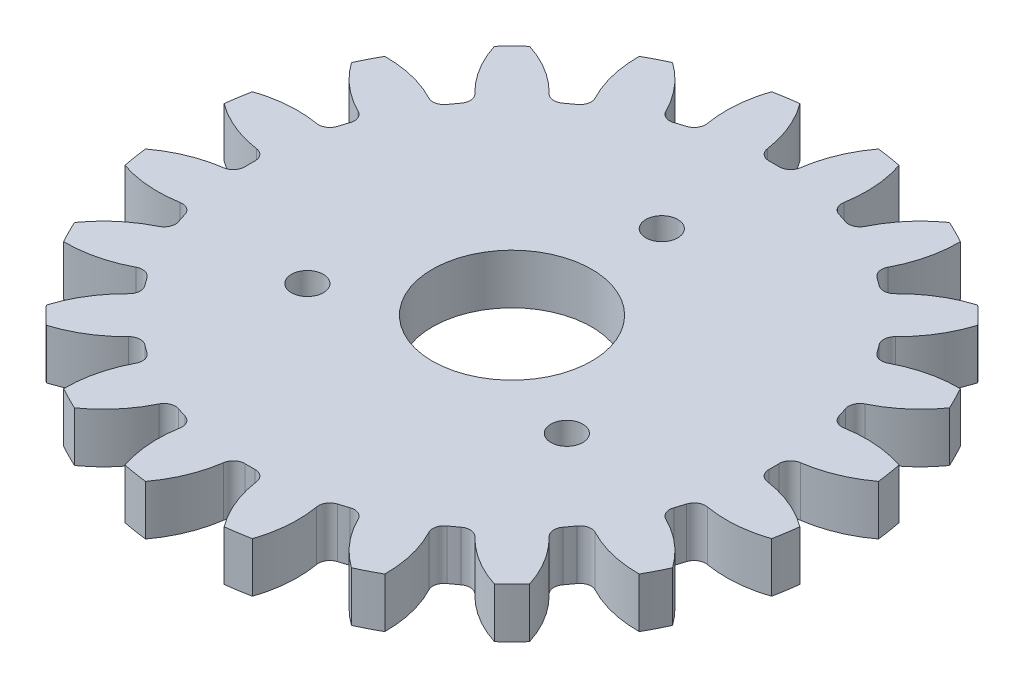
from build123d import *

# Parameters (mm, degrees)
SKETCH2_R                = 33
SKETCH2_R_2              = 7.975
BOSS_EXTRUDE1_DEPTH      = 5
CUT_EXTRUDE1_DEPTH       = 6
FILLET1_R                = 1.14
CIRPATTERN1_COUNT        = 20
FILLET1_OF_CIRPATTERN1_R = 1.14
SKETCH6_R                = 1.6
CUT_EXTRUDE3_DEPTH       = 6.0000001


with BuildPart() as part:
    # Sketch2 → Boss-Extrude1 (new body)
    with BuildSketch(Plane(origin=(0, 0, 0), x_dir=(1, 0, 0), z_dir=(0, 1, 0))):
        Circle(SKETCH2_R)
        Circle(SKETCH2_R_2, mode=Mode.SUBTRACT)
    extrude(amount=BOSS_EXTRUDE1_DEPTH)

    # Sketch3 → Cut-Extrude1 (cut, through all)
    with BuildSketch(Plane(origin=(0, 5, 0), x_dir=(1, 0, 0), z_dir=(0, 1, 0))):
        with BuildLine():
            ThreePointArc((1.54561618, 26.204457076), (0, 26.25), (-1.54561618, 26.204457076))
            ThreePointArc((-1.54561618, 26.204457076), (-2.260255479, 29.659029471), (-3.933366347, 32.764746744))
            ThreePointArc((-3.933366347, 32.764746744), (0, 33), (3.933366347, 32.764746744))
            ThreePointArc((3.933366347, 32.764746744), (2.260255479, 29.659029471), (1.54561618, 26.204457076))
        make_face()
    cut_extrude1 = extrude(amount=-CUT_EXTRUDE1_DEPTH, mode=Mode.SUBTRACT)

    # Fillet1
    fillet1_edges = [part.edges().sort_by_distance(p)[0] for p in [
        (-1.54561618, 2.5, -26.204457076),
        (1.54561618, 2.5, -26.204457076),
    ]]
    fillet(fillet1_edges, radius=FILLET1_R)

    # CirPattern1: Cut-Extrude1 ×20 about axis
    cirpattern1_axis = Axis((0, 0, 0), (0, 1, 0))
    for i in range(1, CIRPATTERN1_COUNT):
        add(cut_extrude1.rotate(cirpattern1_axis, i * 360 / CIRPATTERN1_COUNT), mode=Mode.SUBTRACT)

    # Fillet1 of CirPattern1
    fillet1_of_cirpattern1_edges = [part.edges().sort_by_distance(p)[0] for p in [
        (-9.567590904, 2.5, -24.444297991),
        (-6.627654225, 2.5, -25.399541324),
        (-16.65302317, 2.5, -20.291360706),
        (-14.152163657, 2.5, -22.108341499),
        (-22.108341499, 2.5, -14.152163657),
        (-20.291360706, 2.5, -16.65302317),
        (-25.399541324, 2.5, -6.627654225),
        (-24.444297991, 2.5, -9.567590904),
        (-26.204457076, 2.5, 1.54561618),
        (-26.204457076, 2.5, -1.54561618),
        (-24.444297991, 2.5, 9.567590904),
        (-25.399541324, 2.5, 6.627654225),
        (-20.291360706, 2.5, 16.65302317),
        (-22.108341499, 2.5, 14.152163657),
        (-14.152163657, 2.5, 22.108341499),
        (-16.65302317, 2.5, 20.291360706),
        (-6.627654225, 2.5, 25.399541324),
        (-9.567590904, 2.5, 24.444297991),
        (1.54561618, 2.5, 26.204457076),
        (-1.54561618, 2.5, 26.204457076),
        (9.567590904, 2.5, 24.444297991),
        (6.627654225, 2.5, 25.399541324),
        (16.65302317, 2.5, 20.291360706),
        (14.152163657, 2.5, 22.108341499),
        (22.108341499, 2.5, 14.152163657),
        (20.291360706, 2.5, 16.65302317),
        (25.399541324, 2.5, 6.627654225),
        (24.444297991, 2.5, 9.567590904),
        (26.204457076, 2.5, -1.54561618),
        (26.204457076, 2.5, 1.54561618),
        (24.444297991, 2.5, -9.567590904),
        (25.399541324, 2.5, -6.627654225),
        (20.291360706, 2.5, -16.65302317),
        (22.108341499, 2.5, -14.152163657),
        (14.152163657, 2.5, -22.108341499),
        (16.65302317, 2.5, -20.291360706),
        (6.627654225, 2.5, -25.399541324),
        (9.567590904, 2.5, -24.444297991),
    ]]
    fillet(fillet1_of_cirpattern1_edges, radius=FILLET1_OF_CIRPATTERN1_R)

    # Sketch6 → Cut-Extrude3 (cut, through all)
    with BuildSketch(Plane(origin=(0, 5, 0), x_dir=(1, 0, 0), z_dir=(0, 1, 0))):
        with Locations((0, 15)):
            Circle(SKETCH6_R)
        with Locations((12.990381057, -7.5)):
            Circle(SKETCH6_R)
        with Locations((-12.990381057, -7.5)):
            Circle(SKETCH6_R)
    extrude(amount=-CUT_EXTRUDE3_DEPTH, mode=Mode.SUBTRACT)


solid = part.part
